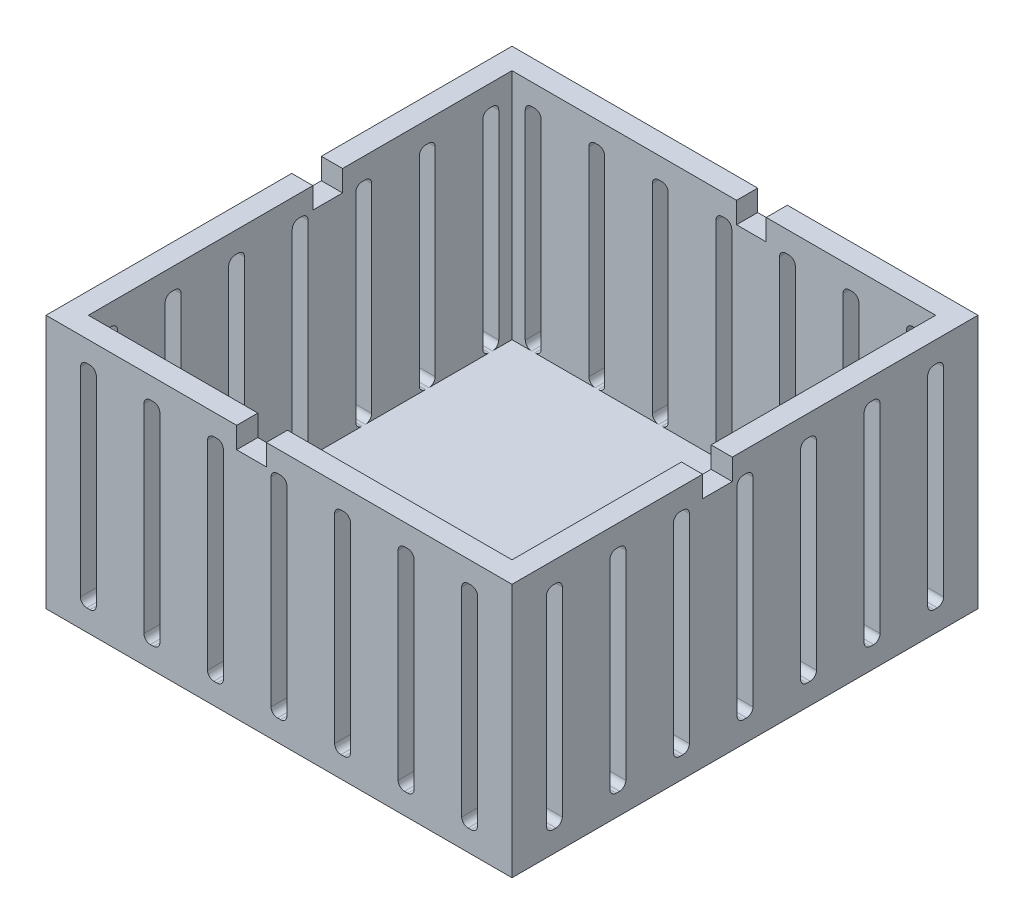
from build123d import *

# Parameters (mm, degrees)
SKETCH2_W           = 55.88
SKETCH2_H           = 55.88
BOSS_EXTRUDE1_DEPTH = 30.48
SKETCH3_W           = 50.8
SKETCH3_H           = 50.8
CUT_EXTRUDE1_DEPTH  = 27.94
CUT_EXTRUDE2_DEPTH  = 55.88
CUT_EXTRUDE3_DEPTH  = 55.88
SKETCH6_W           = 3.556
SKETCH6_H           = 2.54
CUT_EXTRUDE4_DEPTH  = 2.54
SKETCH7_W           = 3.556
SKETCH7_H           = 2.54
CUT_EXTRUDE5_DEPTH  = 2.54
SKETCH8_W           = 3.556
SKETCH8_H           = 2.54
CUT_EXTRUDE6_DEPTH  = 2.54
SKETCH9_W           = 3.556
SKETCH9_H           = 2.54
CUT_EXTRUDE7_DEPTH  = 2.54


with BuildPart() as part:
    # Sketch2 → Boss-Extrude1 (new body)
    with BuildSketch(Plane(origin=(0, 0, 0), x_dir=(1, 0, 0), z_dir=(0, 1, 0))):
        with Locations((27.94, -27.94)):
            Rectangle(SKETCH2_W, SKETCH2_H)
    extrude(amount=BOSS_EXTRUDE1_DEPTH)

    # Sketch3 → Cut-Extrude1 (cut)
    with BuildSketch(Plane(origin=(0, 30.48, 0), x_dir=(1, 0, 0), z_dir=(0, 1, 0))):
        with Locations((27.94, -27.94)):
            Rectangle(SKETCH3_W, SKETCH3_H)
    extrude(amount=-CUT_EXTRUDE1_DEPTH, mode=Mode.SUBTRACT)

    # Sketch4 → Cut-Extrude2 (cut)
    with BuildSketch(Plane.XY.offset(55.88)):
        with BuildLine():
            Line((27.7495, 27.94), (28.1305, 27.94))
            ThreePointArc((28.1305, 27.94), (28.669315367, 27.716815367), (28.8925, 27.178))
            Line((28.8925, 27.178), (28.8925, 3.302))
            ThreePointArc((28.8925, 3.302), (28.669315367, 2.763184633), (28.1305, 2.54))
            Line((28.1305, 2.54), (27.7495, 2.54))
            ThreePointArc((27.7495, 2.54), (27.210684633, 2.763184633), (26.9875, 3.302))
            Line((26.9875, 3.302), (26.9875, 27.178))
            ThreePointArc((26.9875, 27.178), (27.210684633, 27.716815367), (27.7495, 27.94))
        make_face()
        with BuildLine():
            Line((34.6075, 27.178), (34.6075, 3.302))
            ThreePointArc((34.6075, 3.302), (34.830684633, 2.763184633), (35.3695, 2.54))
            Line((35.3695, 2.54), (35.7505, 2.54))
            ThreePointArc((35.7505, 2.54), (36.289315367, 2.763184633), (36.5125, 3.302))
            Line((36.5125, 3.302), (36.5125, 27.178))
            ThreePointArc((36.5125, 27.178), (36.289315367, 27.716815367), (35.7505, 27.94))
            Line((35.7505, 27.94), (35.3695, 27.94))
            ThreePointArc((35.3695, 27.94), (34.830684633, 27.716815367), (34.6075, 27.178))
        make_face()
        with BuildLine():
            Line((42.2275, 27.178), (42.2275, 3.302))
            ThreePointArc((42.2275, 3.302), (42.450684633, 2.763184633), (42.9895, 2.54))
            Line((42.9895, 2.54), (43.3705, 2.54))
            ThreePointArc((43.3705, 2.54), (43.909315367, 2.763184633), (44.1325, 3.302))
            Line((44.1325, 3.302), (44.1325, 27.178))
            ThreePointArc((44.1325, 27.178), (43.909315367, 27.716815367), (43.3705, 27.94))
            Line((43.3705, 27.94), (42.9895, 27.94))
            ThreePointArc((42.9895, 27.94), (42.450684633, 27.716815367), (42.2275, 27.178))
        make_face()
        with BuildLine():
            Line((49.8475, 27.178), (49.8475, 3.302))
            ThreePointArc((49.8475, 3.302), (50.070684633, 2.763184633), (50.6095, 2.54))
            Line((50.6095, 2.54), (50.9905, 2.54))
            ThreePointArc((50.9905, 2.54), (51.529315367, 2.763184633), (51.7525, 3.302))
            Line((51.7525, 3.302), (51.7525, 27.178))
            ThreePointArc((51.7525, 27.178), (51.529315367, 27.716815367), (50.9905, 27.94))
            Line((50.9905, 27.94), (50.6095, 27.94))
            ThreePointArc((50.6095, 27.94), (50.070684633, 27.716815367), (49.8475, 27.178))
        make_face()
        with BuildLine():
            Line((19.3675, 27.178), (19.3675, 3.302))
            ThreePointArc((19.3675, 3.302), (19.590684633, 2.763184633), (20.1295, 2.54))
            Line((20.1295, 2.54), (20.5105, 2.54))
            ThreePointArc((20.5105, 2.54), (21.049315367, 2.763184633), (21.2725, 3.302))
            Line((21.2725, 3.302), (21.2725, 27.178))
            ThreePointArc((21.2725, 27.178), (21.049315367, 27.716815367), (20.5105, 27.94))
            Line((20.5105, 27.94), (20.1295, 27.94))
            ThreePointArc((20.1295, 27.94), (19.590684633, 27.716815367), (19.3675, 27.178))
        make_face()
        with BuildLine():
            Line((11.7475, 27.178), (11.7475, 3.302))
            ThreePointArc((11.7475, 3.302), (11.970684633, 2.763184633), (12.5095, 2.54))
            Line((12.5095, 2.54), (12.8905, 2.54))
            ThreePointArc((12.8905, 2.54), (13.429315367, 2.763184633), (13.6525, 3.302))
            Line((13.6525, 3.302), (13.6525, 27.178))
            ThreePointArc((13.6525, 27.178), (13.429315367, 27.716815367), (12.8905, 27.94))
            Line((12.8905, 27.94), (12.5095, 27.94))
            ThreePointArc((12.5095, 27.94), (11.970684633, 27.716815367), (11.7475, 27.178))
        make_face()
        with BuildLine():
            Line((4.1275, 27.178), (4.1275, 3.302))
            ThreePointArc((4.1275, 3.302), (4.350684633, 2.763184633), (4.8895, 2.54))
            Line((4.8895, 2.54), (5.2705, 2.54))
            ThreePointArc((5.2705, 2.54), (5.809315367, 2.763184633), (6.0325, 3.302))
            Line((6.0325, 3.302), (6.0325, 27.178))
            ThreePointArc((6.0325, 27.178), (5.809315367, 27.716815367), (5.2705, 27.94))
            Line((5.2705, 27.94), (4.8895, 27.94))
            ThreePointArc((4.8895, 27.94), (4.350684633, 27.716815367), (4.1275, 27.178))
        make_face()
    extrude(amount=-CUT_EXTRUDE2_DEPTH, mode=Mode.SUBTRACT)

    # Sketch5 → Cut-Extrude3 (cut)
    with BuildSketch(Plane.ZY):
        with BuildLine():
            Line((28.1305, 27.94), (27.7495, 27.94))
            ThreePointArc((27.7495, 27.94), (27.210684633, 27.716815367), (26.9875, 27.178))
            Line((26.9875, 27.178), (26.9875, 3.302))
            ThreePointArc((26.9875, 3.302), (27.210684633, 2.763184633), (27.7495, 2.54))
            Line((27.7495, 2.54), (28.1305, 2.54))
            ThreePointArc((28.1305, 2.54), (28.669315367, 2.763184633), (28.8925, 3.302))
            Line((28.8925, 3.302), (28.8925, 27.178))
            ThreePointArc((28.8925, 27.178), (28.669315367, 27.716815367), (28.1305, 27.94))
        make_face()
        with BuildLine():
            ThreePointArc((35.3695, 27.94), (34.830684633, 27.716815367), (34.6075, 27.178))
            Line((34.6075, 27.178), (34.6075, 3.302))
            ThreePointArc((34.6075, 3.302), (34.830684633, 2.763184633), (35.3695, 2.54))
            Line((35.3695, 2.54), (35.7505, 2.54))
            ThreePointArc((35.7505, 2.54), (36.289315367, 2.763184633), (36.5125, 3.302))
            Line((36.5125, 3.302), (36.5125, 27.178))
            ThreePointArc((36.5125, 27.178), (36.289315367, 27.716815367), (35.7505, 27.94))
            Line((35.7505, 27.94), (35.3695, 27.94))
        make_face()
        with BuildLine():
            ThreePointArc((42.9895, 27.94), (42.450684633, 27.716815367), (42.2275, 27.178))
            Line((42.2275, 27.178), (42.2275, 3.302))
            ThreePointArc((42.2275, 3.302), (42.450684633, 2.763184633), (42.9895, 2.54))
            Line((42.9895, 2.54), (43.3705, 2.54))
            ThreePointArc((43.3705, 2.54), (43.909315367, 2.763184633), (44.1325, 3.302))
            Line((44.1325, 3.302), (44.1325, 27.178))
            ThreePointArc((44.1325, 27.178), (43.909315367, 27.716815367), (43.3705, 27.94))
            Line((43.3705, 27.94), (42.9895, 27.94))
        make_face()
        with BuildLine():
            ThreePointArc((50.6095, 27.94), (50.070684633, 27.716815367), (49.8475, 27.178))
            Line((49.8475, 27.178), (49.8475, 3.302))
            ThreePointArc((49.8475, 3.302), (50.070684633, 2.763184633), (50.6095, 2.54))
            Line((50.6095, 2.54), (50.9905, 2.54))
            ThreePointArc((50.9905, 2.54), (51.529315367, 2.763184633), (51.7525, 3.302))
            Line((51.7525, 3.302), (51.7525, 27.178))
            ThreePointArc((51.7525, 27.178), (51.529315367, 27.716815367), (50.9905, 27.94))
            Line((50.9905, 27.94), (50.6095, 27.94))
        make_face()
        with BuildLine():
            ThreePointArc((20.1295, 27.94), (19.590684633, 27.716815367), (19.3675, 27.178))
            Line((19.3675, 27.178), (19.3675, 3.302))
            ThreePointArc((19.3675, 3.302), (19.590684633, 2.763184633), (20.1295, 2.54))
            Line((20.1295, 2.54), (20.5105, 2.54))
            ThreePointArc((20.5105, 2.54), (21.049315367, 2.763184633), (21.2725, 3.302))
            Line((21.2725, 3.302), (21.2725, 27.178))
            ThreePointArc((21.2725, 27.178), (21.049315367, 27.716815367), (20.5105, 27.94))
            Line((20.5105, 27.94), (20.1295, 27.94))
        make_face()
        with BuildLine():
            ThreePointArc((12.5095, 27.94), (11.970684633, 27.716815367), (11.7475, 27.178))
            Line((11.7475, 27.178), (11.7475, 3.302))
            ThreePointArc((11.7475, 3.302), (11.970684633, 2.763184633), (12.5095, 2.54))
            Line((12.5095, 2.54), (12.8905, 2.54))
            ThreePointArc((12.8905, 2.54), (13.429315367, 2.763184633), (13.6525, 3.302))
            Line((13.6525, 3.302), (13.6525, 27.178))
            ThreePointArc((13.6525, 27.178), (13.429315367, 27.716815367), (12.8905, 27.94))
            Line((12.8905, 27.94), (12.5095, 27.94))
        make_face()
        with BuildLine():
            ThreePointArc((4.8895, 27.94), (4.350684633, 27.716815367), (4.1275, 27.178))
            Line((4.1275, 27.178), (4.1275, 3.302))
            ThreePointArc((4.1275, 3.302), (4.350684633, 2.763184633), (4.8895, 2.54))
            Line((4.8895, 2.54), (5.2705, 2.54))
            ThreePointArc((5.2705, 2.54), (5.809315367, 2.763184633), (6.0325, 3.302))
            Line((6.0325, 3.302), (6.0325, 27.178))
            ThreePointArc((6.0325, 27.178), (5.809315367, 27.716815367), (5.2705, 27.94))
            Line((5.2705, 27.94), (4.8895, 27.94))
        make_face()
    extrude(amount=-CUT_EXTRUDE3_DEPTH, mode=Mode.SUBTRACT)

    # Sketch6 → Cut-Extrude4 (cut)
    with BuildSketch(Plane.ZY):
        with Locations((24.638, 29.21)):
            Rectangle(SKETCH6_W, SKETCH6_H)
    extrude(amount=-CUT_EXTRUDE4_DEPTH, mode=Mode.SUBTRACT)

    # Sketch7 → Cut-Extrude5 (cut)
    with BuildSketch(Plane(origin=(0, 0, 0), x_dir=(-1, 0, 0), z_dir=(0, 0, -1))):
        with Locations((-31.242, 29.21)):
            Rectangle(SKETCH7_W, SKETCH7_H)
    extrude(amount=-CUT_EXTRUDE5_DEPTH, mode=Mode.SUBTRACT)

    # Sketch8 → Cut-Extrude6 (cut)
    with BuildSketch(Plane(origin=(55.88, 0, 0), x_dir=(0, 0, -1), z_dir=(1, 0, 0))):
        with Locations((-31.242, 29.21)):
            Rectangle(SKETCH8_W, SKETCH8_H)
    extrude(amount=-CUT_EXTRUDE6_DEPTH, mode=Mode.SUBTRACT)

    # Sketch9 → Cut-Extrude7 (cut)
    with BuildSketch(Plane.XY.offset(55.88)):
        with Locations((24.638, 29.21)):
            Rectangle(SKETCH9_W, SKETCH9_H)
    extrude(amount=-CUT_EXTRUDE7_DEPTH, mode=Mode.SUBTRACT)


solid = part.part
